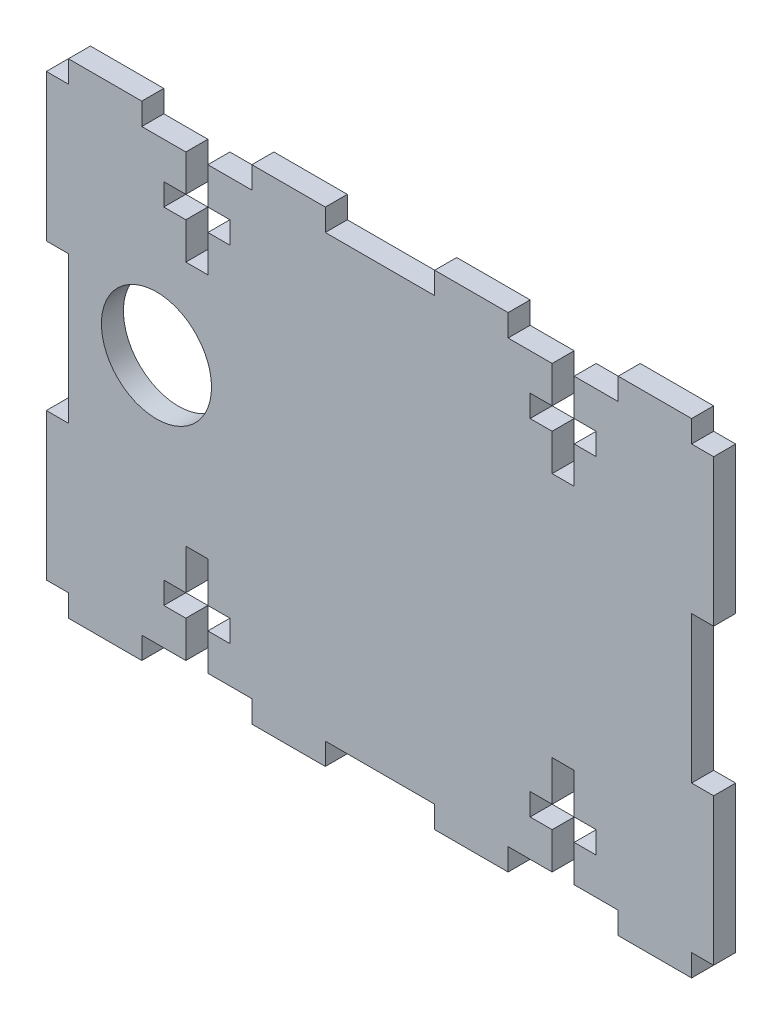
from build123d import *

# Parameters (mm, degrees)
MODEL_R             = 7.5
BOSS_EXTRUDE1_DEPTH = 3


with BuildPart() as part:
    # Model → Boss-Extrude1 (new body)
    with BuildSketch(Plane.XY):
        Polygon((21, -151.199653678), (18, -151.199653678), (18, -148.199653678), (21, -148.199653678), (21, -142.699653678), (24, -142.699653678), (24, -148.199653678), (27, -148.199653678), (27, -151.199653678), (24, -151.199653678), (24, -156.199653678), (30, -156.199653678), (30, -159.199653678), (40, -159.199653678), (40, -156.199653678), (54.9, -156.199653678), (54.9, -159.199653678), (64.9, -159.199653678), (64.9, -156.199653678), (70.9, -156.199653678), (70.9, -151.199653678), (67.9, -151.199653678), (67.9, -148.199653678), (70.9, -148.199653678), (70.9, -142.699653678), (73.9, -142.699653678), (73.9, -148.199653678), (76.9, -148.199653678), (76.9, -151.199653678), (73.9, -151.199653678), (73.9, -156.199653678), (79.9, -156.199653678), (79.9, -159.199653678), (89.9, -159.199653678), (89.9, -156.199653678), (92.9, -156.199653678), (92.9, -136.199653678), (89.9, -136.199653678), (89.9, -116.199653678), (92.9, -116.199653678), (92.9, -96.199653678), (89.9, -96.199653678), (89.9, -93.199653678), (79.9, -93.199653678), (79.9, -96.199653678), (73.9, -96.199653678), (73.9, -101.199653678), (76.9, -101.199653678), (76.9, -104.196392179), (73.9, -104.196392179), (73.9, -109.196392179), (70.9, -109.196392179), (70.9, -104.196392179), (67.9, -104.196392179), (67.9, -101.199653678), (70.9, -101.199653678), (70.9, -96.199653678), (64.9, -96.199653678), (64.9, -93.199653678), (54.9, -93.199653678), (54.9, -96.199653678), (40, -96.199653678), (40, -93.199653678), (30, -93.199653678), (30, -96.199653678), (24, -96.199653678), (24, -101.199653678), (27, -101.199653678), (27, -104.196392179), (24, -104.196392179), (24, -109.196392179), (21, -109.196392179), (21, -104.196392179), (18, -104.196392179), (18, -101.199653678), (21, -101.199653678), (21, -96.199653678), (15, -96.199653678), (15, -93.199653678), (5, -93.199653678), (5, -96.199653678), (2, -96.199653678), (2, -116.199653678), (5, -116.199653678), (5, -136.199653678), (2, -136.199653678), (2, -156.199653678), (5, -156.199653678), (5, -159.199653678), (15, -159.199653678), (15, -156.199653678), (21, -156.199653678), align=None)
        with Locations((17, -122.199653678)):
            Circle(MODEL_R, mode=Mode.SUBTRACT)
    extrude(amount=BOSS_EXTRUDE1_DEPTH)


solid = part.part
